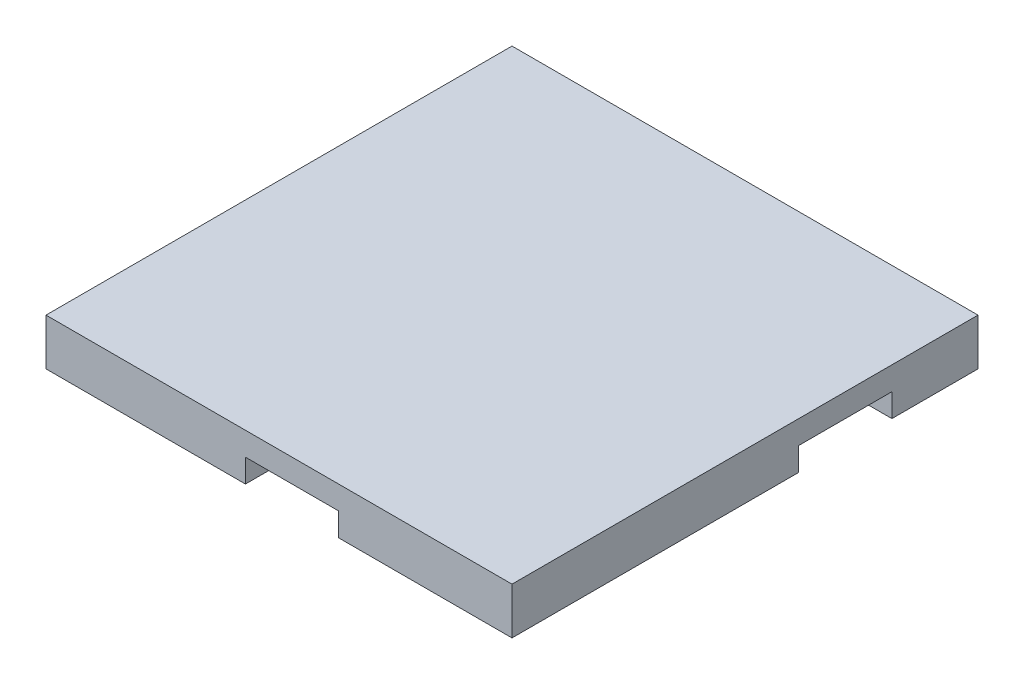
from build123d import *

# Parameters (mm, degrees)
SKIZZE1_W                       = 100
SKIZZE1_H                       = 100
AUFSATZ_LINEAR_AUSTRAGEN1_DEPTH = 10
SCHNITT_LINEAR_AUSTRAGEN1_DEPTH = 5


with BuildPart() as part:
    # Skizze1 → Aufsatz-Linear austragen1 (new body)
    with BuildSketch(Plane(origin=(0, 0, 0), x_dir=(1, 0, 0), z_dir=(0, 1, 0))):
        Rectangle(SKIZZE1_W, SKIZZE1_H)
    extrude(amount=AUFSATZ_LINEAR_AUSTRAGEN1_DEPTH)

    # Skizze3 → Schnitt-Linear austragen1 (cut)
    with BuildSketch(Plane(origin=(0, 0, 0), x_dir=(1, 0, 0), z_dir=(0, 1, 0))):
        with BuildLine():
            Line((50, 31.52163249), (-35.561044575, 31.52163249))
            Line((-35.561044575, 31.52163249), (-35.561044575, -22.426016782))
            Line((-35.561044575, -22.426016782), (-7.198956111, -22.426016782))
            Line((-7.198956111, -22.426016782), (-7.198956111, -50))
            ThreePointArc((-7.198956111, -50), (2.801043889, -60), (12.801043889, -50))
            Line((12.801043889, -50), (12.801043889, -2.426016782))
            Line((12.801043889, -2.426016782), (-15.561044575, -2.426016782))
            Line((-15.561044575, -2.426016782), (-15.561044575, 11.52163249))
            Line((-15.561044575, 11.52163249), (50, 11.52163249))
            ThreePointArc((50, 11.52163249), (60, 21.52163249), (50, 31.52163249))
        make_face()
    extrude(amount=SCHNITT_LINEAR_AUSTRAGEN1_DEPTH, mode=Mode.SUBTRACT)


solid = part.part
